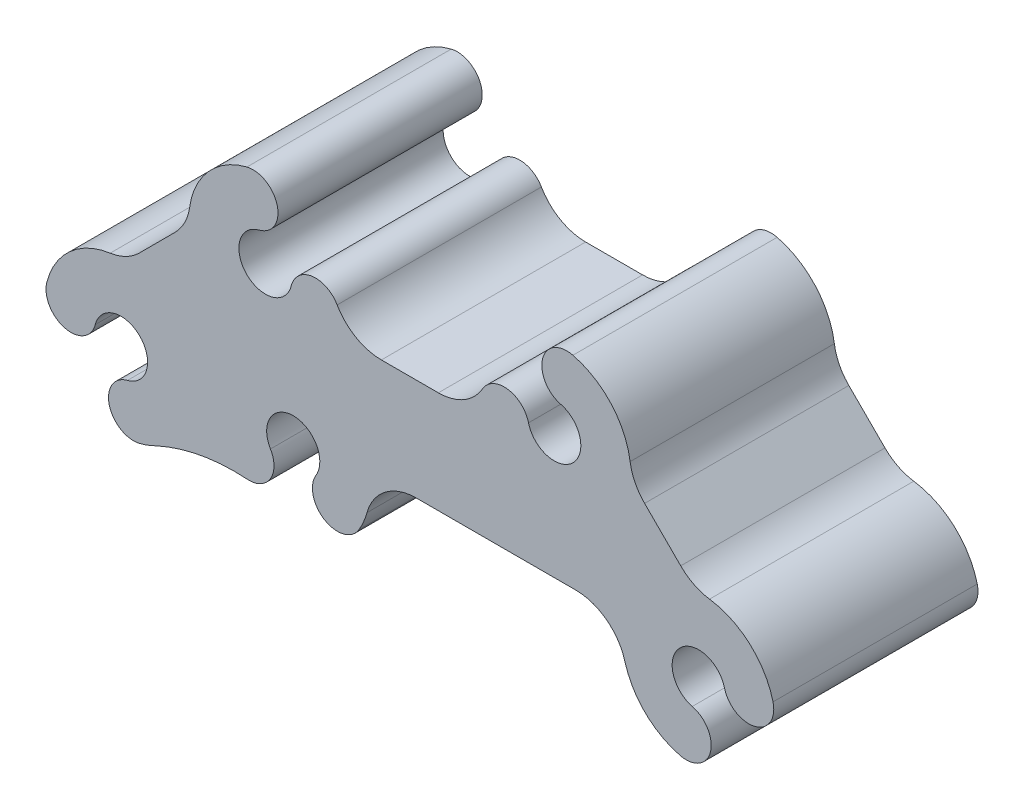
from build123d import *

# Parameters (mm, degrees)
EXTRUDE1_DEPTH = 12.7


with BuildPart() as part:
    # Sketch1 → Extrude1 (new body, symmetric)
    with BuildSketch(Plane.XY):
        with BuildLine():
            Line((3.541744722, 6.350000317), (-3.541744722, 6.350000317))
            ThreePointArc((-3.541744722, 6.350000317), (-6.717339471, 7.201082424), (-9.041692685, 9.526189926))
            ThreePointArc((-9.041692685, 9.526189926), (-12.168838665, 11.052363462), (-14.755482048, 8.724806019))
            ThreePointArc((-14.755482048, 8.724806019), (-20.272604103, 7.166406874), (-18.823535008, 12.713247635))
            ThreePointArc((-18.823535008, 12.713247635), (-16.4863366, 16.468880196), (-20.266433142, 18.766301026))
            ThreePointArc((-20.266433142, 18.766301026), (-25.058481671, 15.875940516), (-27.400098665, 10.793151634))
            ThreePointArc((-27.400098665, 10.793151634), (-28.012836895, 8.894644494), (-29.184374008, 7.27993762))
            Line((-29.184374008, 7.27993762), (-33.668197009, 2.789809368))
            ThreePointArc((-33.668197009, 2.789809368), (-35.320246571, 1.597881998), (-37.264713426, 0.990422317))
            ThreePointArc((-37.264713426, 0.990422317), (-42.296938103, -1.364178798), (-45.159399664, -6.125874443))
            ThreePointArc((-45.159399664, -6.125874443), (-42.896712959, -9.899879208), (-39.1227081, -7.637192526))
            ThreePointArc((-39.1227081, -7.637192526), (-33.584022437, -6.104926504), (-35.119498005, -11.642723169))
            ThreePointArc((-35.119498005, -11.642723169), (-37.384371438, -15.415416021), (-33.611678586, -17.680289454))
            ThreePointArc((-33.611678586, -17.680289454), (-32.609025986, -17.370294909), (-31.646563329, -16.951875875))
            ThreePointArc((-31.646563329, -16.951875875), (-26.066681379, -15.174096844), (-20.21993522, -14.840719891))
            ThreePointArc((-20.21993522, -14.840719891), (-17.353189866, -13.362481197), (-17.337180754, -10.137087846))
            ThreePointArc((-17.337180754, -10.137087846), (-14.434495922, -5.136768789), (-11.74460461, -10.254703395))
            ThreePointArc((-11.74460461, -10.254703395), (-10.54959622, -14.439704472), (-6.339625545, -13.335881127))
            ThreePointArc((-6.339625545, -13.335881127), (-5.758478435, -12.199696418), (-5.334434584, -10.996021018))
            ThreePointArc((-5.334434584, -10.996021018), (-3.058049309, -7.643184473), (0.782668949, -6.35))
            Line((0.782668949, -6.35), (20.629531136, -6.35))
            ThreePointArc((20.629531136, -6.35), (24.469498585, -7.642614313), (26.746128433, -10.994204727))
            ThreePointArc((26.746128433, -10.994204727), (29.278173872, -15.26179643), (33.613137194, -17.676684799))
            ThreePointArc((33.613137194, -17.676684799), (37.385829768, -15.411811583), (35.120956636, -11.639118675))
            ThreePointArc((35.120956636, -11.639118675), (33.586157492, -6.100645238), (39.124630957, -7.635444299))
            ThreePointArc((39.124630957, -7.635444299), (42.897323989, -9.900317715), (45.162197311, -6.127624707))
            ThreePointArc((45.162197311, -6.127624707), (42.301720517, -1.363571666), (37.269569316, 0.993541642))
            ThreePointArc((37.269569316, 0.993541642), (35.33100147, 1.598861028), (33.682682253, 2.785242337))
            Line((33.682682253, 2.785242337), (29.191501523, 7.268011131))
            ThreePointArc((29.191501523, 7.268011131), (27.998435311, 8.921281589), (27.390796294, 10.867427785))
            ThreePointArc((27.390796294, 10.867427785), (25.0373104, 15.90083737), (20.275755297, 18.764698607))
            ThreePointArc((20.275755297, 18.764698607), (16.501386803, 16.503215052), (18.762343911, 12.728531392))
            ThreePointArc((18.762343911, 12.728531392), (20.292630817, 7.189814806), (14.755356019, 8.725310571))
            ThreePointArc((14.755356019, 8.725310571), (12.168581157, 11.052399567), (9.041692685, 9.526189926))
            ThreePointArc((9.041692685, 9.526189926), (6.717339471, 7.201082424), (3.541744722, 6.350000317))
        make_face()
    extrude(amount=EXTRUDE1_DEPTH, both=True)


solid = part.part
